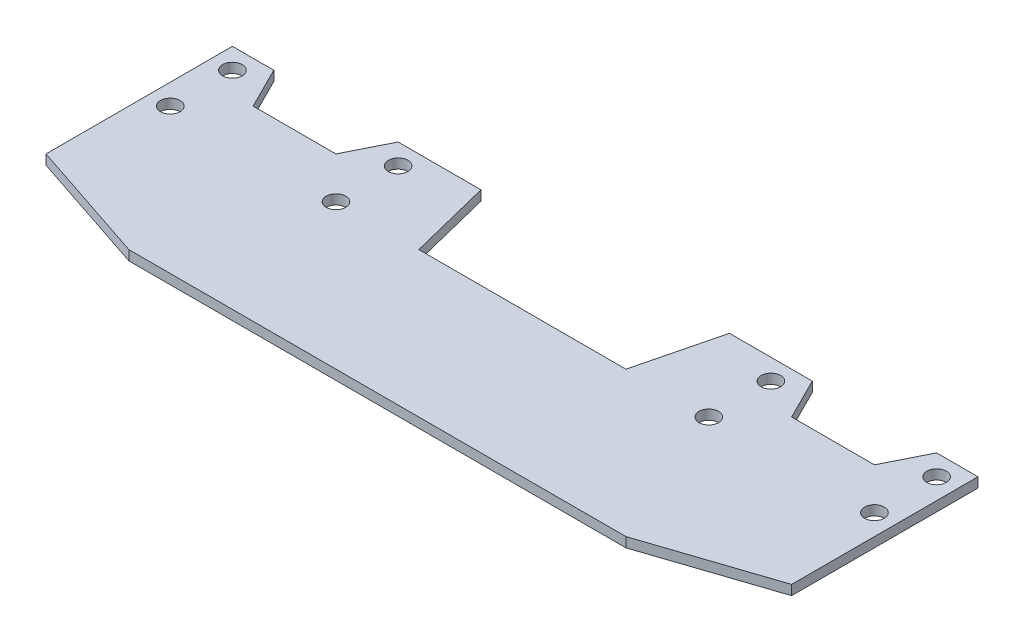
from build123d import *

# Parameters (mm, degrees)
BOSS_EXTRUDE1_DEPTH     = 1.498487888
SKETCH2_R               = 1.5
CUT_EXTRUDE1_DEPTH      = 2.498487888
CUT_EXTRUDE2_DEPTH      = 2.498487888
LPATTERN1_COUNT         = 2
LPATTERN1_PITCH         = 9.525
MIRROR1_COPY_1_SKETCH_R = 1.5
MIRROR1_COPY_1_DEPTH    = 2.498487888


with BuildPart() as part:
    # Sketch1 → Boss-Extrude1 (new body)
    with BuildSketch(Plane(origin=(0, 0, 0), x_dir=(1, 0, 0), z_dir=(0, 1, 0))):
        Polygon((-57.15, -11.1125), (-38.1, -17.4625), (38.1, -17.4625), (57.15, -11.1125), (57.15, 17.4625), (19.05, 17.4625), (15.875, 4.7625), (-15.875, 4.7625), (-19.05, 17.4625), (-57.15, 17.4625), align=None)
    extrude(amount=BOSS_EXTRUDE1_DEPTH)

    # Sketch2 → Cut-Extrude1 (cut, through all)
    with BuildSketch(Plane(origin=(0, 1.498487888, 0), x_dir=(1, 0, 0), z_dir=(0, 1, 0))):
        with Locations((-53.975, 14.2875)):
            Circle(SKETCH2_R)
        with Locations((-28.575, 14.2875)):
            Circle(SKETCH2_R)
    cut_extrude1 = extrude(amount=-CUT_EXTRUDE1_DEPTH, mode=Mode.SUBTRACT)

    # Sketch5 → Cut-Extrude2 (cut, through all)
    with BuildSketch(Plane(origin=(0, 1.498487888, 0), x_dir=(1, 0, 0), z_dir=(0, 1, 0))):
        Polygon((-50.8, 17.4625), (-47.625, 11.1125), (-34.925, 11.1125), (-31.75, 17.4625), align=None)
    cut_extrude2 = extrude(amount=-CUT_EXTRUDE2_DEPTH, mode=Mode.SUBTRACT)

    # LPattern1: Cut-Extrude1 ×2
    with Locations(*[(0, 0, i * LPATTERN1_PITCH) for i in range(1, LPATTERN1_COUNT)]):
        add(cut_extrude1, mode=Mode.SUBTRACT)

    # Mirror1: Cut-Extrude2, Cut-Extrude1 across plane
    add(cut_extrude2.mirror(Plane(origin=(0, 0, 0), x_dir=(0, 0, 1), z_dir=(1, 0, 0))), mode=Mode.SUBTRACT)
    add(cut_extrude1.mirror(Plane(origin=(0, 0, 0), x_dir=(0, 0, 1), z_dir=(1, 0, 0))), mode=Mode.SUBTRACT)

    # Mirror1 copy 1 sketch → Mirror1 copy 1 (cut, through all)
    with BuildSketch(Plane(origin=(0, 1.498487888, 9.525), x_dir=(-1, 0, 0), z_dir=(0, 1, 0))):
        with Locations((-53.975, -14.2875)):
            Circle(MIRROR1_COPY_1_SKETCH_R)
        with Locations((-28.575, -14.2875)):
            Circle(MIRROR1_COPY_1_SKETCH_R)
    extrude(amount=-MIRROR1_COPY_1_DEPTH, mode=Mode.SUBTRACT)


solid = part.part
